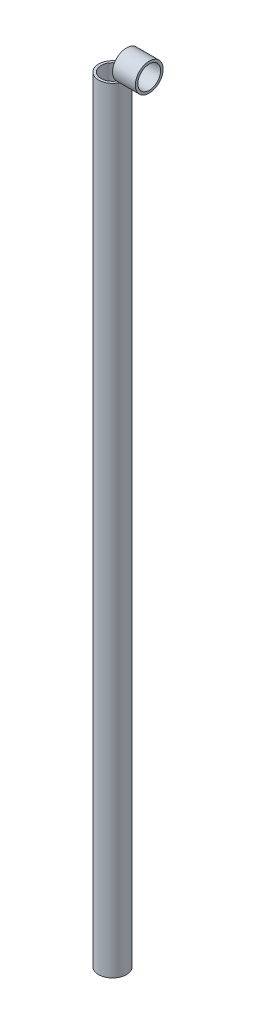
from build123d import *

# Parameters (mm, degrees)
SKETCH1_R           = 17.4625
SKETCH1_R_2         = 14.2875
BOSS_EXTRUDE1_DEPTH = 971.55
BOSS_EXTRUDE2_START = 17.4625
SKETCH2_R           = 17.4625
SKETCH2_R_2         = 14.2875
BOSS_EXTRUDE2_DEPTH = 28.575


with BuildPart() as part:
    # Sketch1 → Boss-Extrude1 (new body)
    with BuildSketch(Plane(origin=(0, 0, 0), x_dir=(1, 0, 0), z_dir=(0, 1, 0))):
        Circle(SKETCH1_R)
        Circle(SKETCH1_R_2, mode=Mode.SUBTRACT)
    extrude(amount=BOSS_EXTRUDE1_DEPTH)


with BuildPart() as body_2:
    # Sketch2 → Boss-Extrude2 (new body)
    with BuildSketch(Plane(origin=(0, 0, 0), x_dir=(0, 0, -1), z_dir=(1, 0, 0)).offset(BOSS_EXTRUDE2_START)):
        with Locations((0, 989.0125)):
            Circle(SKETCH2_R)
        with Locations((0, 989.0125)):
            Circle(SKETCH2_R_2, mode=Mode.SUBTRACT)
    extrude(amount=BOSS_EXTRUDE2_DEPTH)


solid = Compound([part.part, body_2.part])
